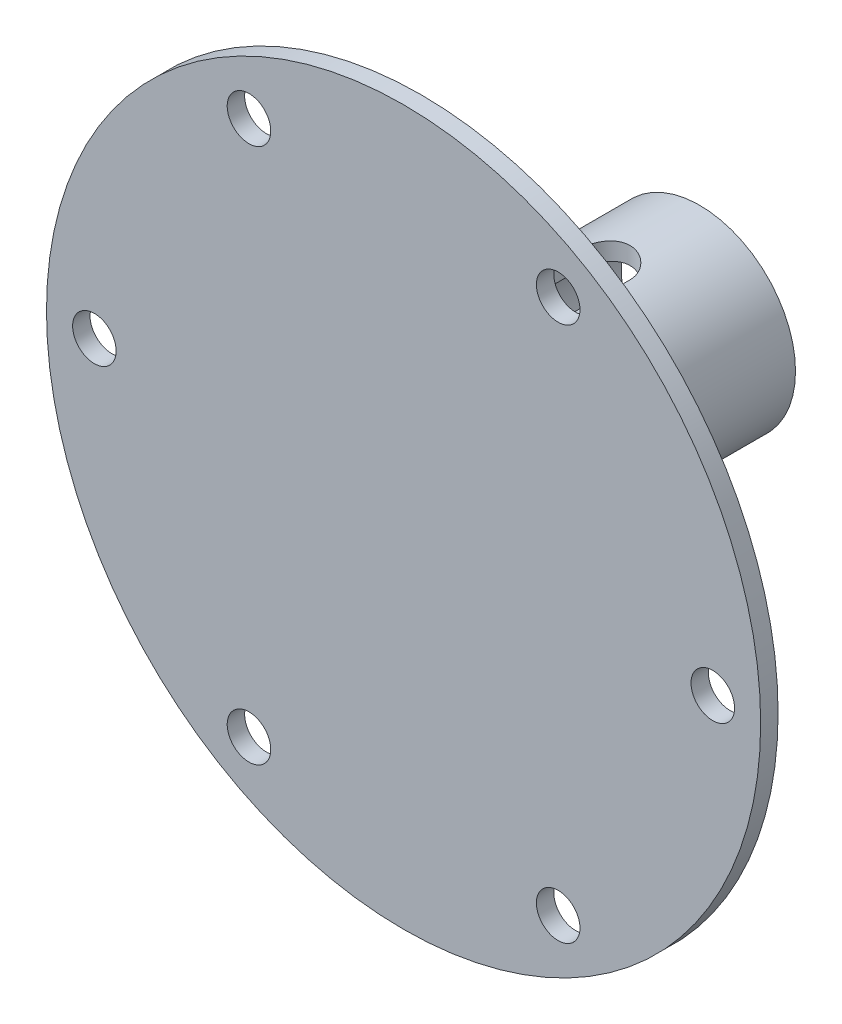
from build123d import *

# Parameters (mm, degrees)
SKETCH1_R               = 11
SKETCH1_R_2             = 9
BOSS_EXTRUDE1_DEPTH     = 32
CUT_EXTRUDE1_DEPTH      = 15
CUT_EXTRUDE1_DEPTH_BACK = 9
SKETCH3_R               = 41
BOSS_EXTRUDE2_DEPTH     = 2
FILLET1_R               = 2
SKETCH4_R               = 2.5
CUT_EXTRUDE2_DEPTH      = 2


with BuildPart() as part:
    # Sketch1 → Boss-Extrude1 (new body)
    with BuildSketch(Plane.XY):
        with Locations((0, 3)):
            Circle(SKETCH1_R)
        with Locations((0, 3)):
            Circle(SKETCH1_R_2, mode=Mode.SUBTRACT)
    extrude(amount=-BOSS_EXTRUDE1_DEPTH)

    # Sketch2 → Cut-Extrude1 (cut, two sides)
    with BuildSketch(Plane(origin=(0, 0, 0), x_dir=(1, 0, 0), z_dir=(0, 1, 0))) as cut_extrude1_sk:
        with BuildLine():
            Line((3, 21), (3, 6))
            ThreePointArc((3, 6), (0, 3), (-3, 6))
            Line((-3, 6), (-3, 21))
            ThreePointArc((-3, 21), (0, 24), (3, 21))
        make_face()
    extrude(amount=CUT_EXTRUDE1_DEPTH, mode=Mode.SUBTRACT)
    extrude(cut_extrude1_sk.sketch, amount=-CUT_EXTRUDE1_DEPTH_BACK, mode=Mode.SUBTRACT)

    # Sketch3 → Boss-Extrude2 (add)
    with BuildSketch(Plane.XY):
        Circle(SKETCH3_R)
    extrude(amount=BOSS_EXTRUDE2_DEPTH)

    # Fillet1
    fillet1_edges = [part.edges().sort_by_distance(p)[0] for p in [
        (-11, 3, 0),
    ]]
    fillet(fillet1_edges, radius=FILLET1_R)

    # Sketch4 → Cut-Extrude2 (cut)
    with BuildSketch(Plane.XY.offset(2)):
        with Locations((35.5, 0)):
            Circle(SKETCH4_R)
        with Locations((17.75, -30.743901834)):
            Circle(SKETCH4_R)
        with Locations((-17.75, -30.743901834)):
            Circle(SKETCH4_R)
        with Locations((-35.5, 0)):
            Circle(SKETCH4_R)
        with Locations((-17.75, 30.743901834)):
            Circle(SKETCH4_R)
        with Locations((17.75, 30.743901834)):
            Circle(SKETCH4_R)
    extrude(amount=-CUT_EXTRUDE2_DEPTH, mode=Mode.SUBTRACT)


solid = part.part
